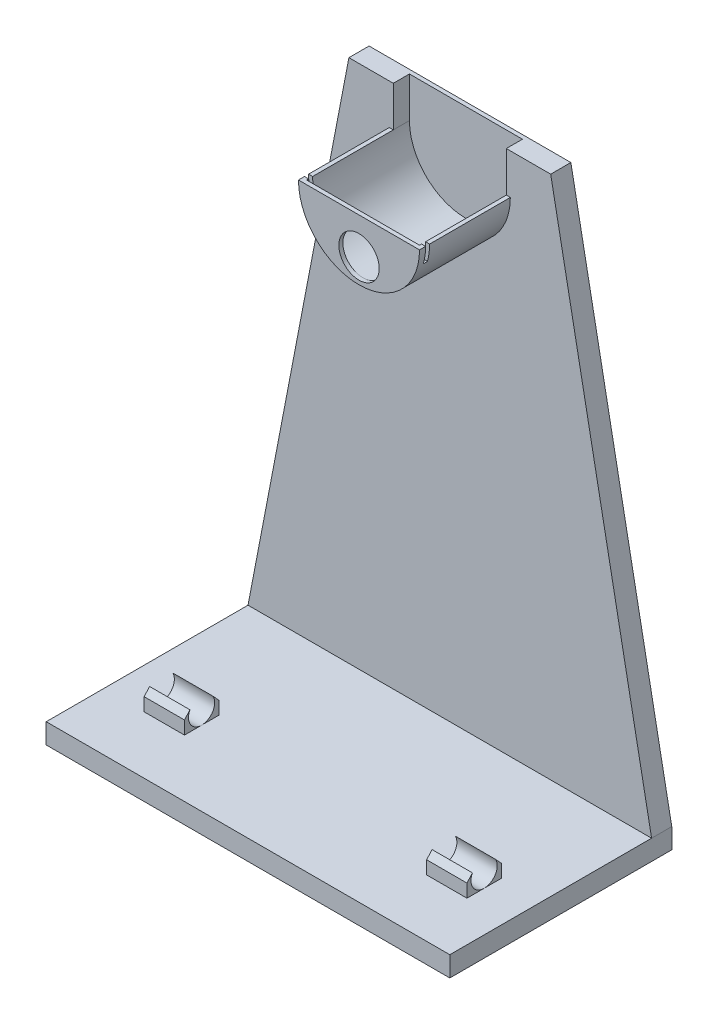
from build123d import *

# Parameters (mm, degrees)
BOSS_EXTRUDE1_DEPTH      = 5
BOSS_EXTRUDE3_DEPTH      = 22.5
CUT_EXTRUDE3_DEPTH       = 21.5
CUT_EXTRUDE3_DEPTH_BACK  = 4
SKETCH2_W                = 100
SKETCH2_H                = 5
BOSS_EXTRUDE2_DEPTH      = 50
SKETCH4_R                = 5
CUT_EXTRUDE1_DEPTH       = 8.5
SKETCH5_W                = 41.64031781
SKETCH5_H                = 1
CUT_EXTRUDE2_DEPTH       = 4
BOSS_EXTRUDE5_DEPTH      = 5
BOSS_EXTRUDE5_DEPTH_BACK = 5
BOSS_EXTRUDE6_DEPTH      = 5
BOSS_EXTRUDE6_DEPTH_BACK = 5


with BuildPart() as part:
    # Sketch1 → Boss-Extrude1 (new body)
    with BuildSketch(Plane.XY):
        Polygon((25, 130), (-25, 130), (-50, 0), (-50, -5), (50, -5), (50, 0), align=None)
    extrude(amount=BOSS_EXTRUDE1_DEPTH)

    # Sketch3 → Boss-Extrude3 (add)
    with BuildSketch(Plane.XY.offset(5)):
        with BuildLine():
            Line((-15, 120), (15, 120))
            ThreePointArc((15, 120), (0, 105), (-15, 120))
        make_face()
    extrude(amount=BOSS_EXTRUDE3_DEPTH)

    # Sketch12 → Cut-Extrude3 (cut, two sides)
    with BuildSketch(Plane.XY.offset(5)) as cut_extrude3_sk:
        with BuildLine():
            Line((-14, 120), (-14, 130))
            Line((-14, 130), (14, 130))
            Line((14, 130), (14, 120))
            ThreePointArc((14, 120), (0, 106), (-14, 120))
        make_face()
    extrude(amount=CUT_EXTRUDE3_DEPTH, mode=Mode.SUBTRACT)
    extrude(cut_extrude3_sk.sketch, amount=-CUT_EXTRUDE3_DEPTH_BACK, mode=Mode.SUBTRACT)

    # Sketch2 → Boss-Extrude2 (add)
    with BuildSketch(Plane.XY.offset(5)):
        with Locations((0, -2.5)):
            Rectangle(SKETCH2_W, SKETCH2_H)
    extrude(amount=BOSS_EXTRUDE2_DEPTH)

    # Sketch4 → Cut-Extrude1 (cut)
    with BuildSketch(Plane.XY.offset(27.5)):
        with Locations((0, 111)):
            Circle(SKETCH4_R)
    extrude(amount=-CUT_EXTRUDE1_DEPTH, mode=Mode.SUBTRACT)

    # Sketch5 → Cut-Extrude2 (cut)
    with BuildSketch(Plane(origin=(0, 120, 0), x_dir=(1, 0, 0), z_dir=(0, 1, 0))):
        with Locations((0.627254623, -25.5)):
            Rectangle(SKETCH5_W, SKETCH5_H)
    extrude(amount=-CUT_EXTRUDE2_DEPTH, mode=Mode.SUBTRACT)

    # Sketch8 → Boss-Extrude5 (add, two sides)
    with BuildSketch(Plane(origin=(-35, 0, 0), x_dir=(0, 0, -1), z_dir=(1, 0, 0))) as boss_extrude5_sk:
        with BuildLine():
            Line((-40.75, 3.25), (-40.75, 0))
            Line((-40.75, 0), (-55, 0))
            Line((-55, 0), (-55, -5))
            Line((-55, -5), (0, -5))
            Line((0, -5), (0, 0))
            Line((0, 0), (-5, 0))
            Line((-5, 0), (-32.25, 0))
            Line((-32.25, 0), (-32.25, 3.25))
            Line((-32.25, 3.25), (-33.616859351, 4.75))
            ThreePointArc((-33.616859351, 4.75), (-36.5, 0), (-39.383140649, 4.75))
            Line((-39.383140649, 4.75), (-40.75, 3.25))
        make_face()
    extrude(amount=BOSS_EXTRUDE5_DEPTH)
    extrude(boss_extrude5_sk.sketch, amount=-BOSS_EXTRUDE5_DEPTH_BACK)

    # Sketch11 → Boss-Extrude6 (add, two sides)
    with BuildSketch(Plane(origin=(35, 0, 0), x_dir=(0, 0, -1), z_dir=(1, 0, 0))) as boss_extrude6_sk:
        with BuildLine():
            Line((-40.75, 3.25), (-40.75, 0))
            Line((-40.75, 0), (-55, 0))
            Line((-55, 0), (-55, -5))
            Line((-55, -5), (0, -5))
            Line((0, -5), (0, 0))
            Line((0, 0), (-5, 0))
            Line((-5, 0), (-32.25, 0))
            Line((-32.25, 0), (-32.25, 3.25))
            Line((-32.25, 3.25), (-33.616859351, 4.75))
            ThreePointArc((-33.616859351, 4.75), (-36.5, 0), (-39.383140649, 4.75))
            Line((-39.383140649, 4.75), (-40.75, 3.25))
        make_face()
    extrude(amount=BOSS_EXTRUDE6_DEPTH)
    extrude(boss_extrude6_sk.sketch, amount=-BOSS_EXTRUDE6_DEPTH_BACK)


solid = part.part
